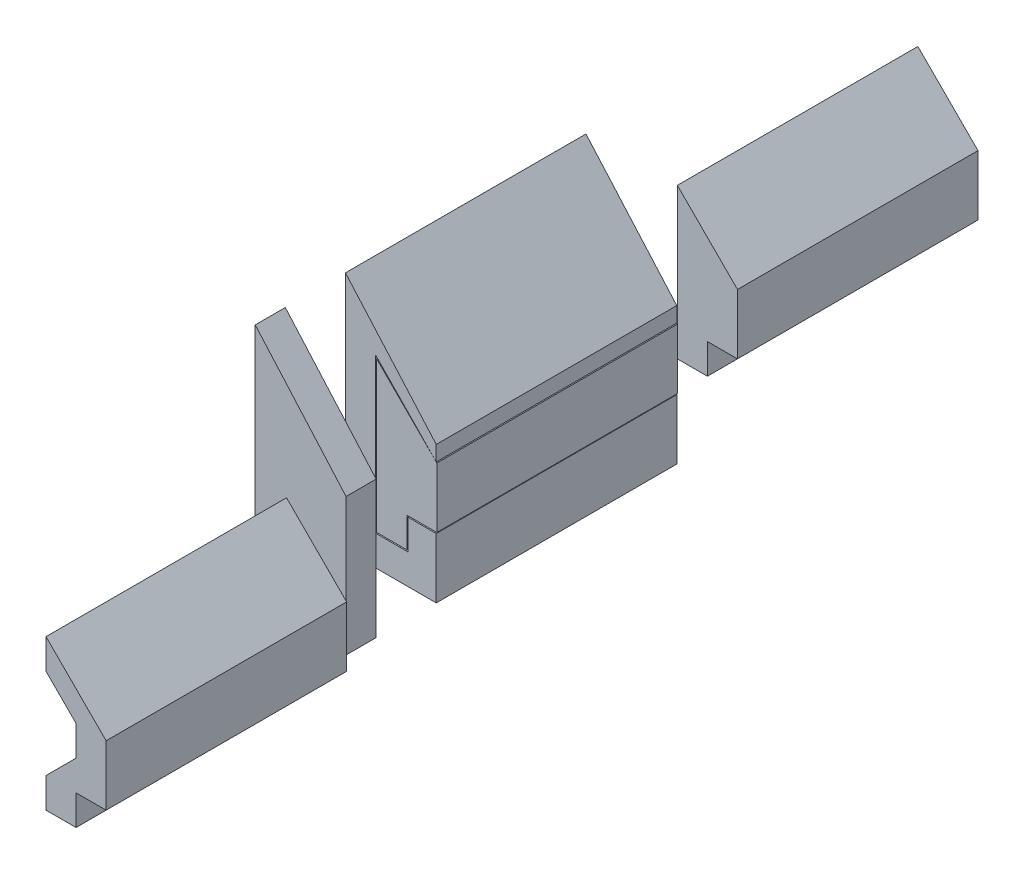
from build123d import *

# Parameters (mm, degrees)
BOSS_EXTRUDE2_DEPTH = 40
BOSS_EXTRUDE3_DEPTH = 40
BOSS_EXTRUDE4_DEPTH = 5
BOSS_EXTRUDE6_DEPTH = 40
BOSS_EXTRUDE7_DEPTH = 40


with BuildPart() as part:
    # female → Boss-Extrude2 (new body)
    with BuildSketch(Plane.XY):
        Polygon((-0.1, -0.2), (-0.1, -10.2), (-15.2, -10.2), (-15.2, 29.8), (-0.1, 12.631933622), (-0.1, 10.102772968), (-10.2, 20.482842712), (-10.2, -5.2), (-4.8, -5.2), (-4.8, -0.2), align=None)
    extrude(amount=BOSS_EXTRUDE2_DEPTH)


with BuildPart() as body_2:
    # male_FULL → Boss-Extrude3 (new body)
    with BuildSketch(Plane.XY):
        Polygon((0, 0), (0, 10), (-10, 20), (-10, -5), (-5, -5), (-5, 0), align=None)
    extrude(amount=BOSS_EXTRUDE3_DEPTH)


with BuildPart() as body_3:
    # female_stop → Boss-Extrude4 (new body)
    with BuildSketch(Plane.XY.offset(50)):
        Polygon((-0.1, -0.2), (-0.1, 10.102772968), (-0.1, 12.631933622), (-15.2, 29.8), (-15.2, -10.2), (-0.1, -10.2), align=None)
    extrude(amount=BOSS_EXTRUDE4_DEPTH)


with BuildPart() as body_4:
    # Sketch6 → Boss-Extrude6 (new body)
    with BuildSketch(Plane.XY.offset(60)):
        Polygon((5, 2.5), (-5, 12.5), (-5, 7.5), (0, 2.5), (0, -2.5), (-5, -7.5), (-5, -12.5), (0, -12.5), (0, -7.5), (5, -7.5), align=None)
    extrude(amount=BOSS_EXTRUDE6_DEPTH)


with BuildPart() as body_5:
    # Sketch7 → Boss-Extrude7 (new body)
    with BuildSketch(Plane(origin=(0, 0, -10), x_dir=(-1, 0, 0), z_dir=(0, 0, -1))):
        Polygon((0, 0), (0, 10), (10, 20), (10, -5), (5, -5), (5, 0), align=None)
    extrude(amount=BOSS_EXTRUDE7_DEPTH)


solid = Compound([part.part, body_2.part, body_3.part, body_4.part, body_5.part])
